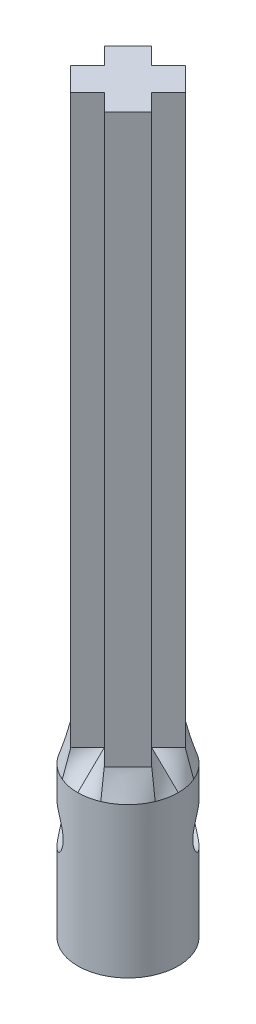
from build123d import *

# Parameters (mm, degrees)
BOSS_EXTRUDE1_DEPTH = 60.739130435
SCALE1_SCALE        = 0.92
SKETCH4_R           = 4.953
SKETCH3_R           = 4.953
BOSS_EXTRUDE2_DEPTH = 14.7955
SKETCH5_R           = 2.032
CUT_EXTRUDE1_DEPTH  = 12.957599916


with BuildPart() as part:
    # Sketch1 → Boss-Extrude1 (new body)
    with BuildSketch(Plane(origin=(0, 0, 0), x_dir=(1, 0, 0), z_dir=(0, 1, 0))):
        Polygon((-0.6269783, 2.91618698), (-2.423029524, 4.712238204), (-4.963029524, 2.172238204), (-3.1669783, 0.37618698), (-4.963029524, -1.419864244), (-2.423029524, -3.959864244), (-0.6269783, -2.16381302), (1.169072924, -3.959864244), (3.709072924, -1.419864244), (1.9130217, 0.37618698), (3.709072924, 2.172238204), (1.169072924, 4.712238204), align=None)
    extrude(amount=BOSS_EXTRUDE1_DEPTH)


with BuildPart() as part_1:
    # Scale1: scaled about (-0.6269783, 30.369565217, -0.37618698)
    add(part.part.scale(SCALE1_SCALE).moved(Location((-0.050158264, 2.429565217, -0.030094958))))

    # Sketch4 → section 1 of loft1
    with BuildSketch(Plane(origin=(0, -0.110434783, 0), x_dir=(-1, 0, 0), z_dir=(0, -1, 0)), mode=Mode.PRIVATE) as loft1_s1:
        with Locations((0.6269783, 0.37618698)):
            Circle(SKETCH4_R)
    # loft from a face of the part (loft1)
    loft([part_1.faces().sort_by_distance((-0.6269783, 2.429565217, -0.37618698))[0], loft1_s1.sketch])

    # Sketch3 → Boss-Extrude2 (add)
    with BuildSketch(Plane(origin=(0, -0.110434783, 0), x_dir=(1, 0, 0), z_dir=(0, 1, 0))):
        with Locations((-0.6269783, 0.37618698)):
            Circle(SKETCH3_R)
    extrude(amount=-BOSS_EXTRUDE2_DEPTH)

    # Sketch5 → Cut-Extrude1 (cut, through all)
    with BuildSketch(Plane(origin=(3.376904227, 0, -3.376904227), x_dir=(-0.707106781, 0, -0.707106781), z_dir=(0.707106781, 0, -0.707106781))):
        with Locations((0.709344972, -5.190434783)):
            Circle(SKETCH5_R)
    extrude(amount=-CUT_EXTRUDE1_DEPTH, mode=Mode.SUBTRACT)


solid = part_1.part
